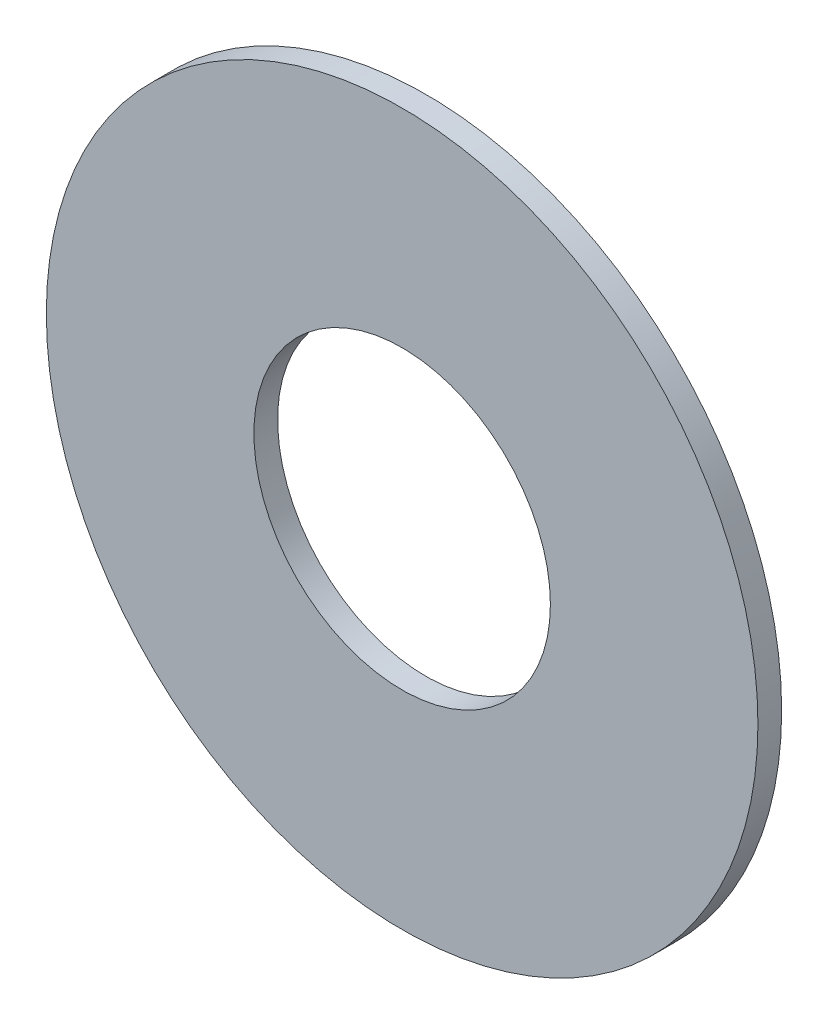
from build123d import *

# Parameters (mm, degrees)
SKETCH1_R           = 190.5
SKETCH1_R_2         = 79.375
BOSS_EXTRUDE1_DEPTH = 12.7


with BuildPart() as part:
    # Sketch1 → Boss-Extrude1 (new body)
    with BuildSketch(Plane.XY):
        Circle(SKETCH1_R)
        Circle(SKETCH1_R_2, mode=Mode.SUBTRACT)
    extrude(amount=BOSS_EXTRUDE1_DEPTH)


solid = part.part
